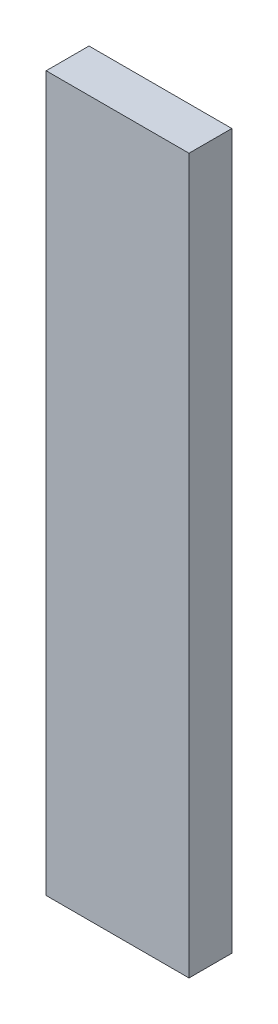
from build123d import *

# Parameters (mm, degrees)
SALIENTE_EXTRUIR1_DEPTH = 3


with BuildPart() as part:
    # Model → Saliente-Extruir1 (new body)
    with BuildSketch(Plane.XY):
        Polygon((20.836408092, 1), (30.836388632, 1), (30.836388632, 51), (25.336388632, 51), (20.836408092, 51), align=None)
    extrude(amount=SALIENTE_EXTRUIR1_DEPTH)


solid = part.part
